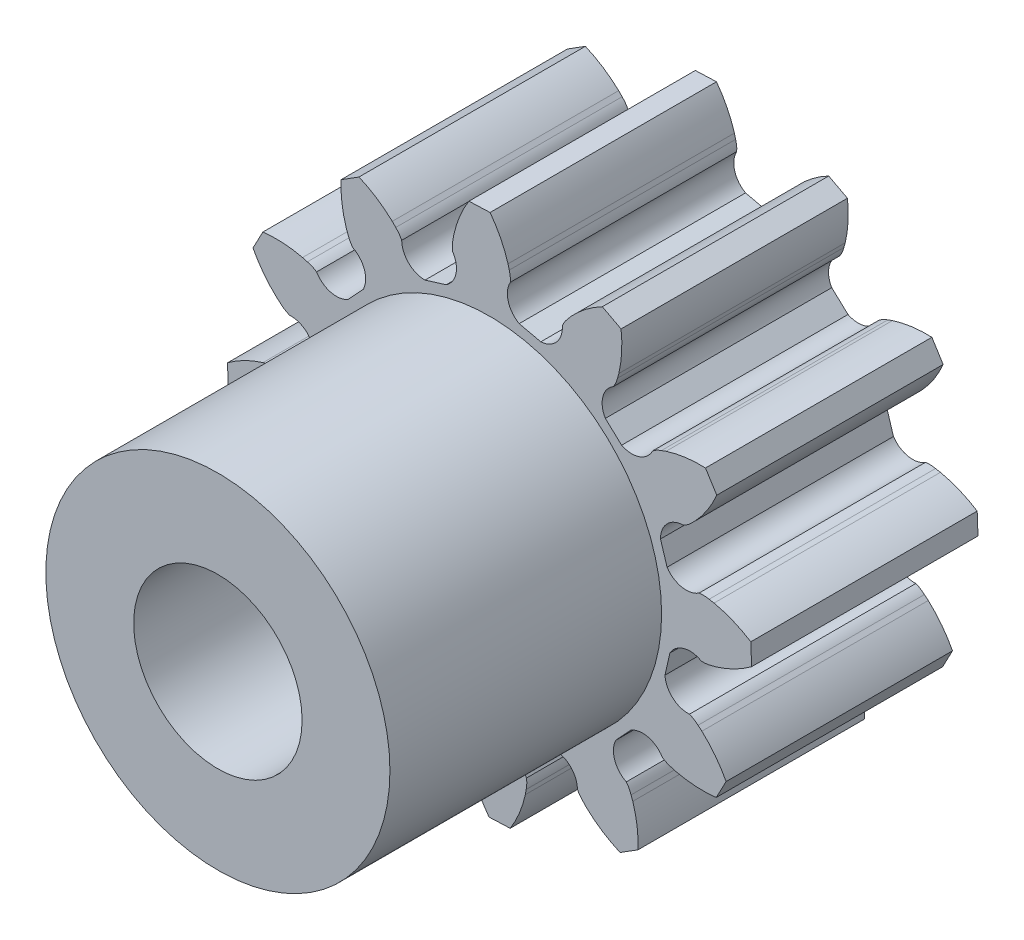
from build123d import *

# Parameters (mm, degrees)
MODEL_R             = 2.3622
BOSS_EXTRUDE1_DEPTH = 6.35
SKETCH2_R           = 4.826
SKETCH2_R_2         = 2.3622
BOSS_EXTRUDE2_DEPTH = 7.62


with BuildPart() as part:
    # Model → Boss-Extrude1 (new body)
    with BuildSketch(Plane.XY):
        with BuildLine():
            Line((60.340481476, 63.998312185), (60.429911035, 64.106057536))
            ThreePointArc((60.429911035, 64.106057536), (60.842262668, 64.484456305), (61.313741722, 64.785997347))
            Line((61.313741722, 64.785997347), (61.839269721, 64.508877032))
            ThreePointArc((61.839269721, 64.508877032), (61.856769657, 63.949490538), (61.777448824, 63.395479975))
            Line((61.777448824, 63.395479975), (61.73905497, 63.260825671))
            ThreePointArc((61.73905497, 63.260825671), (61.69392198, 63.126152726), (61.624784454, 63.002081007))
            ThreePointArc((61.624784454, 63.002081007), (61.32810778, 62.605783997), (61.39855171, 62.115778558))
            Line((61.39855171, 62.115778558), (61.855325367, 61.69275258))
            ThreePointArc((61.855325367, 61.69275258), (62.349286489, 61.660053642), (62.721691389, 61.98621526))
            ThreePointArc((62.721691389, 61.98621526), (62.840104182, 62.064651343), (62.970923841, 62.119968081))
            Line((62.970923841, 62.119968081), (63.102242132, 62.168564522))
            ThreePointArc((63.102242132, 62.168564522), (63.648548506, 62.290091653), (64.207631865, 62.315494328))
            Line((64.207631865, 62.315494328), (64.524192967, 61.812738138))
            ThreePointArc((64.524192967, 61.812738138), (64.259655109, 61.319545255), (63.913955971, 60.87941845))
            Line((63.913955971, 60.87941845), (63.813379233, 60.781999426))
            ThreePointArc((63.813379233, 60.781999426), (63.706956444, 60.68793573), (63.585045731, 60.615055232))
            ThreePointArc((63.585045731, 60.615055232), (63.129969625, 60.42018982), (62.945973275, 59.960612019))
            Line((62.945973275, 59.960612019), (63.130036332, 59.36587405))
            ThreePointArc((63.130036332, 59.36587405), (63.541469743, 59.090575378), (64.027062656, 59.186837175))
            ThreePointArc((64.027062656, 59.186837175), (64.16882882, 59.195561575), (64.309780459, 59.178057442))
            Line((64.309780459, 59.178057442), (64.447806459, 59.154480687))
            ThreePointArc((64.447806459, 59.154480687), (64.981685223, 58.986573082), (65.478566952, 58.729030764))
            Line((65.478566952, 58.729030764), (65.501338761, 58.135353164))
            ThreePointArc((65.501338761, 58.135353164), (65.025645814, 57.840504527), (64.506198176, 57.632193102))
            Line((64.506198176, 57.632193102), (64.370389113, 57.598111721))
            ThreePointArc((64.370389113, 57.598111721), (64.231192426, 57.569861565), (64.089174403, 57.567700559))
            ThreePointArc((64.089174403, 57.567700559), (63.597631497, 57.626483733), (63.208494631, 57.320474381))
            Line((63.208494631, 57.320474381), (63.070530319, 56.713381531))
            ThreePointArc((63.070530319, 56.713381531), (63.289192769, 56.269249182), (63.757859466, 56.109817887))
            ThreePointArc((63.757859466, 56.109817887), (63.884996029, 56.046491887), (63.998312185, 55.96085672))
            Line((63.998312185, 55.96085672), (64.106057536, 55.871427161))
            ThreePointArc((64.106057536, 55.871427161), (64.484456305, 55.459075527), (64.785997347, 54.987596473))
            Line((64.785997347, 54.987596473), (64.508877032, 54.462068475))
            ThreePointArc((64.508877032, 54.462068475), (63.949490538, 54.444568538), (63.395479975, 54.523889372))
            Line((63.395479975, 54.523889372), (63.260825671, 54.562283225))
            ThreePointArc((63.260825671, 54.562283225), (63.126152726, 54.607416216), (63.002081007, 54.676553741))
            ThreePointArc((63.002081007, 54.676553741), (62.605783997, 54.973230416), (62.115778558, 54.902786486))
            Line((62.115778558, 54.902786486), (61.69275258, 54.446012829))
            ThreePointArc((61.69275258, 54.446012829), (61.660053642, 53.952051707), (61.98621526, 53.579646806))
            ThreePointArc((61.98621526, 53.579646806), (62.064651343, 53.461234014), (62.119968081, 53.330414355))
            Line((62.119968081, 53.330414355), (62.168564522, 53.199092249))
            ThreePointArc((62.168564522, 53.199092249), (62.290091653, 52.652785875), (62.315494328, 52.093702516))
            Line((62.315494328, 52.093702516), (61.812738138, 51.777145229))
            ThreePointArc((61.812738138, 51.777145229), (61.319545255, 52.041683087), (60.87941845, 52.387382225))
            Line((60.87941845, 52.387382225), (60.781999426, 52.487958963))
            ThreePointArc((60.781999426, 52.487958963), (60.68793573, 52.594381752), (60.615055232, 52.716292465))
            ThreePointArc((60.615055232, 52.716292465), (60.42018982, 53.17136857), (59.960612019, 53.355364921))
            Line((59.960612019, 53.355364921), (59.36587405, 53.171301864))
            ThreePointArc((59.36587405, 53.171301864), (59.090575378, 52.759868453), (59.186837175, 52.27427554))
            ThreePointArc((59.186837175, 52.27427554), (59.195561634, 52.132507445), (59.178057442, 51.991553922))
            Line((59.178057442, 51.991553922), (59.154480687, 51.853531736))
            ThreePointArc((59.154480687, 51.853531736), (58.986573082, 51.319652973), (58.729030764, 50.822771243))
            Line((58.729030764, 50.822771243), (58.135353164, 50.799999435))
            ThreePointArc((58.135353164, 50.799999435), (57.840504527, 51.275692382), (57.632193102, 51.79514002))
            Line((57.632193102, 51.79514002), (57.598111721, 51.930952897))
            ThreePointArc((57.598111721, 51.930952897), (57.569861565, 52.070149584), (57.567700559, 52.212167607))
            ThreePointArc((57.567700559, 52.212167607), (57.626481485, 52.703707795), (57.320474381, 53.092843565))
            Line((57.320474381, 53.092843565), (56.713381531, 53.230807876))
            ThreePointArc((56.713381531, 53.230807876), (56.269249182, 53.012145427), (56.109817887, 52.54347873))
            ThreePointArc((56.109817887, 52.54347873), (56.046491887, 52.416342167), (55.96085672, 52.30302601))
            Line((55.96085672, 52.30302601), (55.871427161, 52.19528066))
            ThreePointArc((55.871427161, 52.19528066), (55.459075527, 51.816881891), (54.987596473, 51.515340849))
            Line((54.987596473, 51.515340849), (54.462068475, 51.792461164))
            ThreePointArc((54.462068475, 51.792461164), (54.444568538, 52.351847658), (54.523889372, 52.905858221))
            Line((54.523889372, 52.905858221), (54.562283225, 53.040512525))
            ThreePointArc((54.562283225, 53.040512525), (54.607416216, 53.17518547), (54.676553741, 53.299257189))
            ThreePointArc((54.676553741, 53.299257189), (54.973230416, 53.695554199), (54.902786486, 54.185559637))
            Line((54.902786486, 54.185559637), (54.446012829, 54.608585616))
            ThreePointArc((54.446012829, 54.608585616), (53.952051707, 54.641284554), (53.579646806, 54.315122936))
            ThreePointArc((53.579646806, 54.315122936), (53.461234014, 54.236686853), (53.330414355, 54.181370115))
            Line((53.330414355, 54.181370115), (53.199092249, 54.132773673))
            ThreePointArc((53.199092249, 54.132773673), (52.652785875, 54.011246543), (52.093702516, 53.985843868))
            Line((52.093702516, 53.985843868), (51.777145229, 54.488600058))
            ThreePointArc((51.777145229, 54.488600058), (52.041683087, 54.981792941), (52.387382225, 55.421919746))
            Line((52.387382225, 55.421919746), (52.487958963, 55.51933877))
            ThreePointArc((52.487958963, 55.51933877), (52.594381752, 55.613402466), (52.716292465, 55.686282964))
            ThreePointArc((52.716292465, 55.686282964), (53.17136857, 55.881148376), (53.355364921, 56.340726176))
            Line((53.355364921, 56.340726176), (53.171301864, 56.935464146))
            ThreePointArc((53.171301864, 56.935464146), (52.759868453, 57.210762818), (52.27427554, 57.114501021))
            ThreePointArc((52.27427554, 57.114501021), (52.132507445, 57.105776562), (51.991553922, 57.123280753))
            Line((51.991553922, 57.123280753), (51.853531736, 57.146857509))
            ThreePointArc((51.853531736, 57.146857509), (51.319652973, 57.314765114), (50.822771243, 57.572307431))
            Line((50.822771243, 57.572307431), (50.799999435, 58.165985032))
            ThreePointArc((50.799999435, 58.165985032), (51.275692382, 58.460833669), (51.79514002, 58.669145094))
            Line((51.79514002, 58.669145094), (51.930952897, 58.703226475))
            ThreePointArc((51.930952897, 58.703226475), (52.070149584, 58.731476631), (52.212167607, 58.733637637))
            ThreePointArc((52.212167607, 58.733637637), (52.703707795, 58.674856711), (53.092843565, 58.980863815))
            Line((53.092843565, 58.980863815), (53.230807876, 59.587956665))
            ThreePointArc((53.230807876, 59.587956665), (53.012145427, 60.032089014), (52.54347873, 60.191520309))
            ThreePointArc((52.54347873, 60.191520309), (52.416342167, 60.254846309), (52.30302601, 60.340481476))
            Line((52.30302601, 60.340481476), (52.19528066, 60.429911035))
            ThreePointArc((52.19528066, 60.429911035), (51.816881891, 60.842262668), (51.515340849, 61.313741722))
            Line((51.515340849, 61.313741722), (51.792461164, 61.839269721))
            ThreePointArc((51.792461164, 61.839269721), (52.351847658, 61.856769657), (52.905858221, 61.777448824))
            Line((52.905858221, 61.777448824), (53.040512525, 61.73905497))
            ThreePointArc((53.040512525, 61.73905497), (53.17518547, 61.69392198), (53.299257189, 61.624784454))
            ThreePointArc((53.299257189, 61.624784454), (53.695554199, 61.32810778), (54.185559637, 61.39855171))
            Line((54.185559637, 61.39855171), (54.608585616, 61.855325367))
            ThreePointArc((54.608585616, 61.855325367), (54.641284554, 62.349286489), (54.315122936, 62.721691389))
            ThreePointArc((54.315122936, 62.721691389), (54.236686853, 62.840104182), (54.181370115, 62.970923841))
            Line((54.181370115, 62.970923841), (54.132773673, 63.102242132))
            ThreePointArc((54.132773673, 63.102242132), (54.011246543, 63.648548506), (53.985843868, 64.207631865))
            Line((53.985843868, 64.207631865), (54.488600058, 64.524192967))
            ThreePointArc((54.488600058, 64.524192967), (54.981792941, 64.259655109), (55.421919746, 63.913955971))
            Line((55.421919746, 63.913955971), (55.51933877, 63.813379233))
            ThreePointArc((55.51933877, 63.813379233), (55.613402466, 63.706956444), (55.686282964, 63.585045731))
            ThreePointArc((55.686282964, 63.585045731), (55.881148376, 63.129969625), (56.340726176, 62.945973275))
            Line((56.340726176, 62.945973275), (56.935464146, 63.130036332))
            ThreePointArc((56.935464146, 63.130036332), (57.210762818, 63.541469743), (57.114501021, 64.027062656))
            ThreePointArc((57.114501021, 64.027062656), (57.105776621, 64.16882882), (57.123280753, 64.309780459))
            Line((57.123280753, 64.309780459), (57.146857509, 64.447806459))
            ThreePointArc((57.146857509, 64.447806459), (57.314765114, 64.981685223), (57.572307431, 65.478566952))
            Line((57.572307431, 65.478566952), (58.165985032, 65.501338761))
            ThreePointArc((58.165985032, 65.501338761), (58.460833669, 65.025645814), (58.669145094, 64.506198176))
            Line((58.669145094, 64.506198176), (58.703226475, 64.370389113))
            ThreePointArc((58.703226475, 64.370389113), (58.731476631, 64.231192426), (58.733637637, 64.089174403))
            ThreePointArc((58.733637637, 64.089174403), (58.674854463, 63.597631497), (58.980863815, 63.208494631))
            Line((58.980863815, 63.208494631), (59.587956665, 63.070530319))
            ThreePointArc((59.587956665, 63.070530319), (60.032089014, 63.289192769), (60.191520309, 63.757859466))
            ThreePointArc((60.191520309, 63.757859466), (60.254846309, 63.884996029), (60.340481476, 63.998312185))
        make_face()
        with Locations((58.150669098, 58.150669098)):
            Circle(MODEL_R, mode=Mode.SUBTRACT)
    extrude(amount=BOSS_EXTRUDE1_DEPTH)

    # Sketch2 → Boss-Extrude2 (add)
    with BuildSketch(Plane.XY.offset(6.35)):
        with Locations((58.150669098, 58.150669098)):
            Circle(SKETCH2_R)
        with Locations((58.150669098, 58.150669098)):
            Circle(SKETCH2_R_2, mode=Mode.SUBTRACT)
    extrude(amount=BOSS_EXTRUDE2_DEPTH)


solid = part.part
